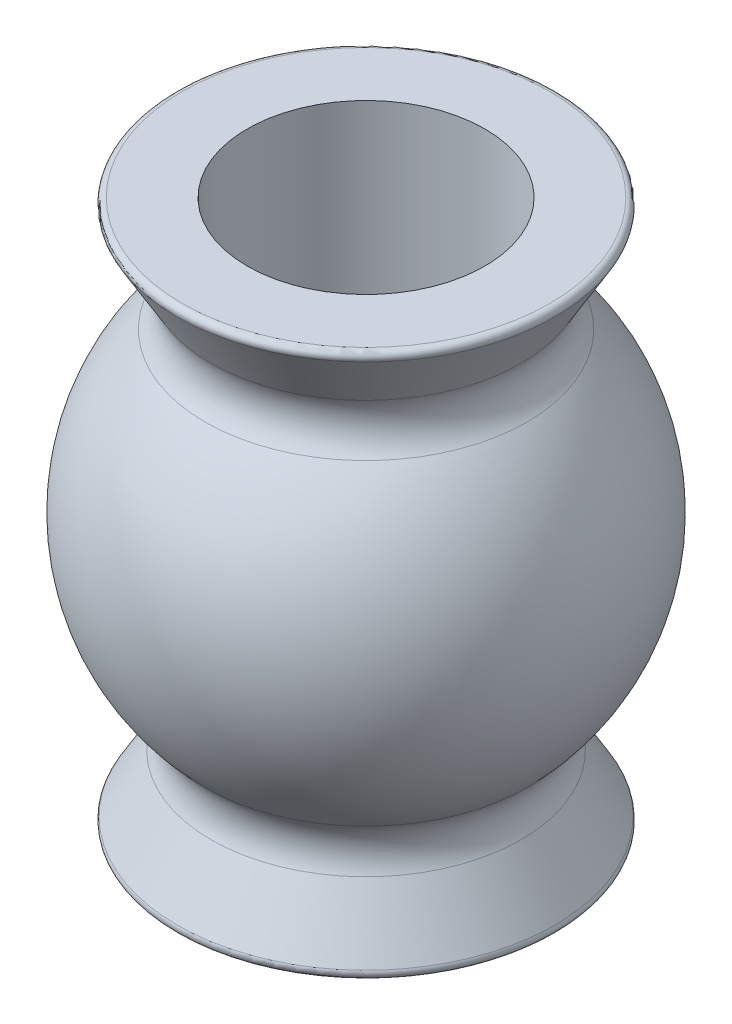
from build123d import *

# Parameters (mm, degrees)
FILLET1_R = 0.508
FILLET2_R = 0.0762


with BuildPart() as part:
    # Sketch1 → Revolve1 (revolve)
    with BuildSketch(Plane.XY, mode=Mode.PRIVATE) as revolve1_sk:
        with BuildLine():
            Line((1.524, 0), (1.524, 6.985))
            Line((1.524, 6.985), (2.4892, 6.985))
            Line((2.4892, 6.985), (1.777274138, 5.7785))
            ThreePointArc((1.777274138, 5.7785), (2.8956, 3.4925), (1.777274138, 1.2065))
            Line((1.777274138, 1.2065), (2.4892, 0))
            Line((2.4892, 0), (1.524, 0))
        make_face()
    revolve(revolve1_sk.sketch.rotate(Axis((0, 0, 0), (0, 1, 0)), 90), axis=Axis((0, 0, 0), (0, 1, 0)))  # turned: the seam where the file's is

    # Fillet1
    fillet1_edges = [part.edges().sort_by_distance(p)[0] for p in [
        (0, 1.2065, 1.777274138),
        (0, 5.7785, 1.777274138),
    ]]
    fillet(fillet1_edges, radius=FILLET1_R)

    # Fillet2
    fillet2_edges = [part.edges().sort_by_distance(p)[0] for p in [
        (0, 0, 2.4892),
        (0, 6.985, 2.4892),
    ]]
    fillet(fillet2_edges, radius=FILLET2_R)


solid = part.part
